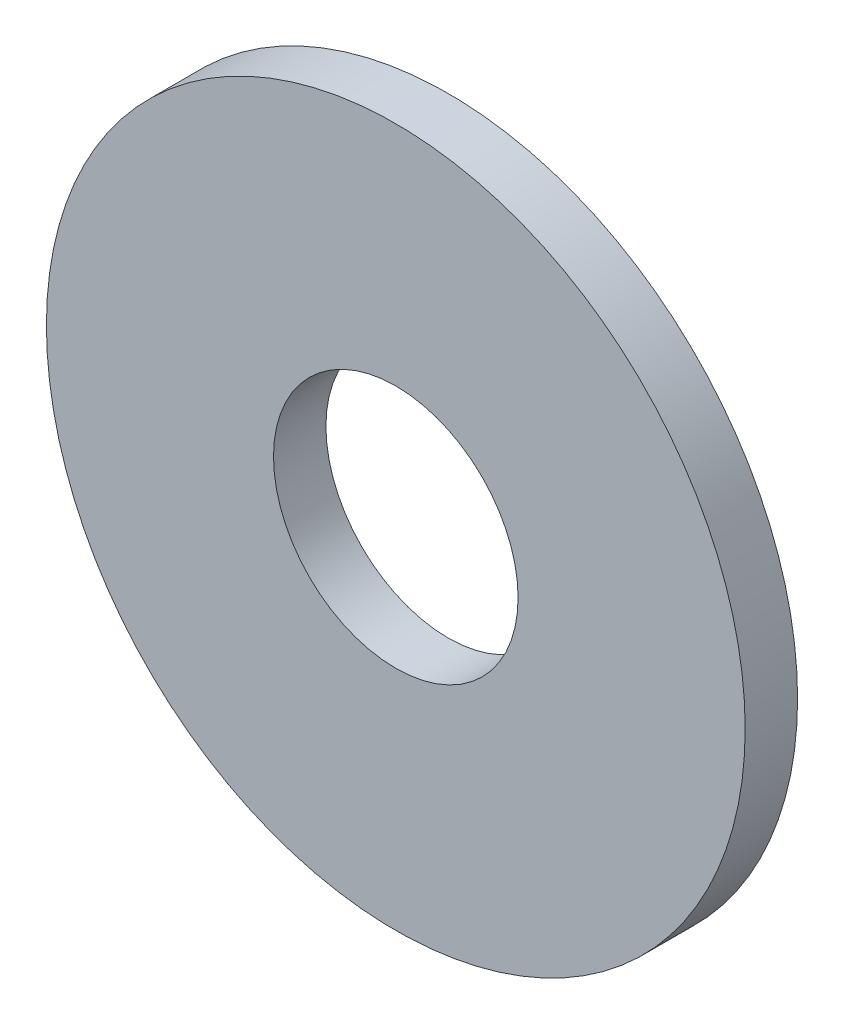
from build123d import *

# Parameters (mm, degrees)
SKETCH1_R      = 12
SKETCH1_R_2    = 4.2
EXTRUDE1_DEPTH = 1.8


with BuildPart() as part:
    # Sketch1 → Extrude1 (new body)
    with BuildSketch(Plane.XY):
        Circle(SKETCH1_R)
        Circle(SKETCH1_R_2, mode=Mode.SUBTRACT)
    extrude(amount=-EXTRUDE1_DEPTH)


solid = part.part
